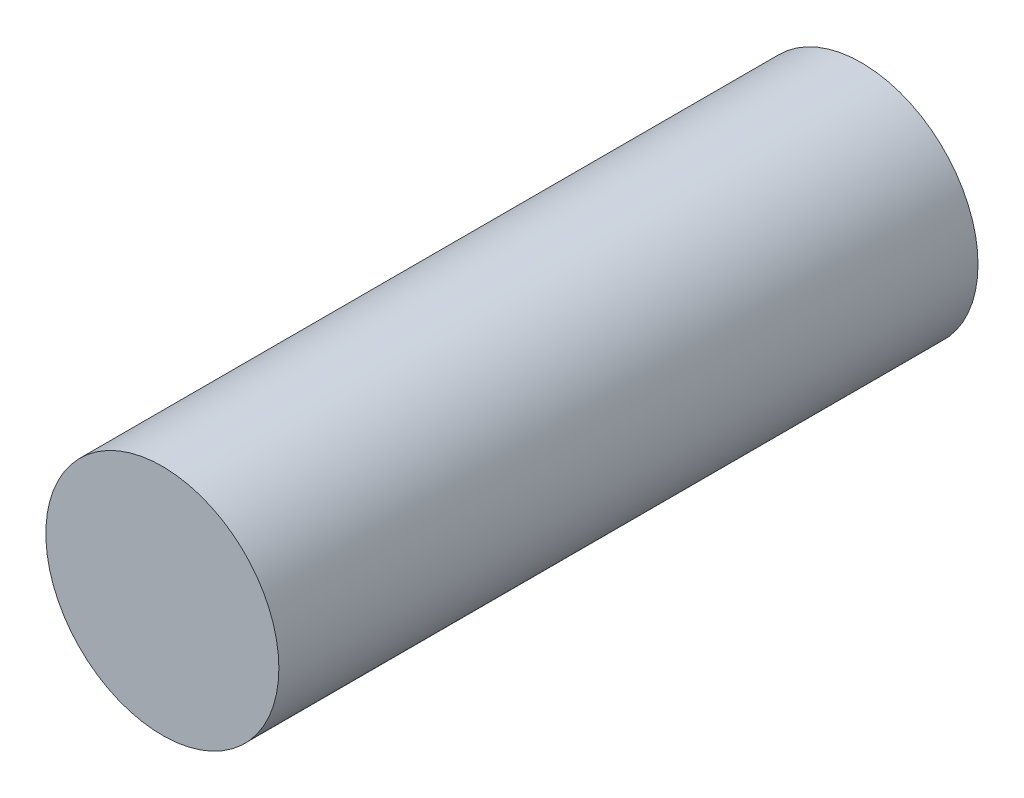
from build123d import *

# Parameters (mm, degrees)
SKETCH1_R           = 2.5
BOSS_EXTRUDE1_DEPTH = 7.5


with BuildPart() as part:
    # Sketch1 → Boss-Extrude1 (new body, symmetric)
    with BuildSketch(Plane.XY):
        Circle(SKETCH1_R)
    extrude(amount=BOSS_EXTRUDE1_DEPTH, both=True)


solid = part.part
